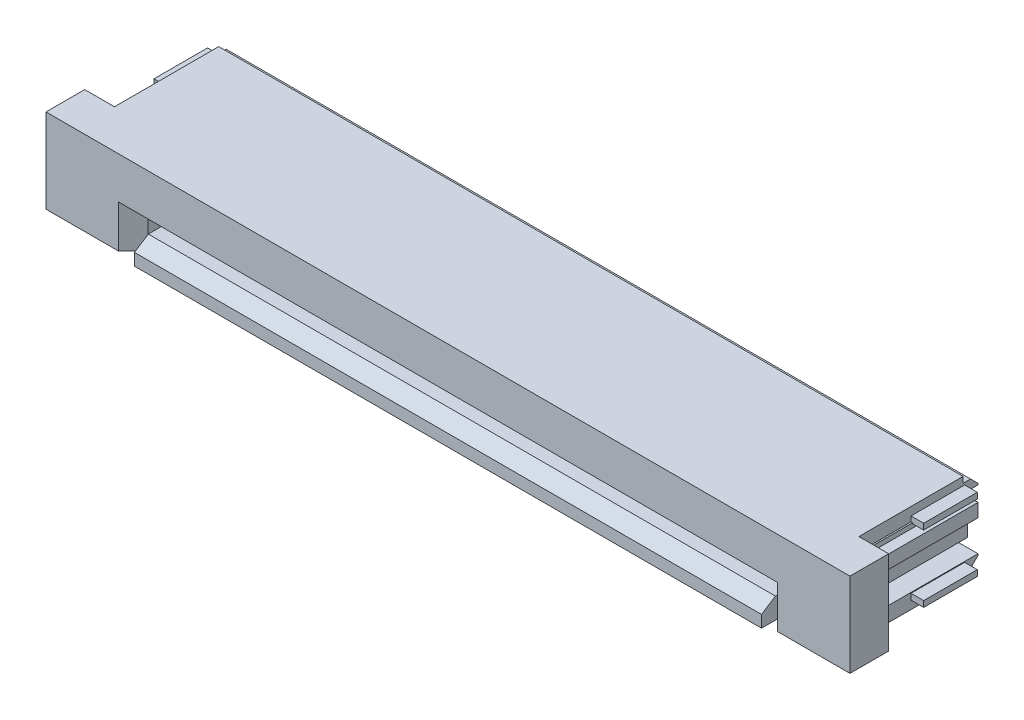
from build123d import *

# Parameters (mm, degrees)
BASE_DEPTH              = 12.5
SKETCH2_W               = 21.2
SKETCH2_H               = 1.55
CARD_SLOT_DEPTH         = 3.8
SKETCH4_W               = 1.775
SKETCH4_H               = 2
WINGS_DEPTH             = 5
SKETCH5_W               = 1.97
SKETCH5_H               = 3
FRONT_LEAD_IN_DEPTH     = 1.3
CARD_SLOT_LEAD_IN_SIZE  = 0.1
CARD_SLOT_LEAD_IN_SIZE2 = 0.173205081
WT_DEPTH                = 1.8
GATE_DEPTH              = 1.3
GATE_CHAMFER_SIZE       = 0.5
GATE_GUIDE_DEPTH        = 3.6
F_01_CONTACT_DEPTH      = 0.125
LPATTERN3_COUNT         = 20
LPATTERN3_PITCH         = 1


with BuildPart() as part:
    # Sketch1 → Base (new body, symmetric)
    with BuildSketch(Plane(origin=(0, 0, 0), x_dir=(0, 0, -1), z_dir=(1, 0, 0))):
        Polygon((-1.75, 1.5), (1.75, 1.5), (1.75, 1.3), (2, 1.3), (2.25, 1.05), (2.25, -1.05), (2, -1.3), (1.75, -1.3), (1.75, -1.5), (-3.05, -1.5), (-3.05, -1.1), (-2.35, -0.65), (-1.75, -0.65), align=None)
    extrude(amount=BASE_DEPTH, both=True)

    # Sketch2 → Card Slot (cut)
    with BuildSketch(Plane.XY.offset(3.05)):
        with Locations((0, -0.025)):
            Rectangle(SKETCH2_W, SKETCH2_H)
    extrude(amount=-CARD_SLOT_DEPTH, mode=Mode.SUBTRACT)

    # Sketch4 → Wings (cut, through all)
    with BuildSketch(Plane.XY.offset(1.75)):
        with Locations((-11.6125, 0)):
            Rectangle(SKETCH4_W, SKETCH4_H)
        with Locations((11.6125, 0)):
            Rectangle(SKETCH4_W, SKETCH4_H)
    extrude(amount=-WINGS_DEPTH, mode=Mode.SUBTRACT)

    # Sketch5 → Front Lead In (cut)
    with BuildSketch(Plane.XY.offset(3.05)):
        with Locations((-11.515, 0)):
            Rectangle(SKETCH5_W, SKETCH5_H)
        with Locations((11.515, 0)):
            Rectangle(SKETCH5_W, SKETCH5_H)
    extrude(amount=-FRONT_LEAD_IN_DEPTH, mode=Mode.SUBTRACT)

    # Card Slot Lead In
    card_slot_lead_in_edges = [part.edges().sort_by_distance(p)[0] for p in [
        (0, 0.75, 1.75),
        (-10.6, -0.025, 1.75),
        (10.6, -0.025, 1.75),
    ]]
    card_slot_lead_in_side = [part.faces().sort_by_distance(p)[0] for p in [
        (0, 0.875692186, 1.75),
    ]]
    chamfer(card_slot_lead_in_edges, length=CARD_SLOT_LEAD_IN_SIZE, length2=CARD_SLOT_LEAD_IN_SIZE2, reference=card_slot_lead_in_side[0])

    # Sketch8 → WT (add)
    with BuildSketch(Plane.XY):
        with BuildLine():
            Line((-12.925, 1.025), (-11.075, 1.025))
            ThreePointArc((-11.075, 1.025), (-10.968933983, 0.981066017), (-10.925, 0.875))
            Line((-10.925, 0.875), (-10.925, -0.875))
            ThreePointArc((-10.925, -0.875), (-10.968933983, -0.981066017), (-11.075, -1.025))
            Line((-11.075, -1.025), (-12.925, -1.025))
            Line((-12.925, -1.025), (-12.925, -1.225))
            Line((-12.925, -1.225), (-11.075, -1.225))
            ThreePointArc((-11.075, -1.225), (-10.827512627, -1.122487373), (-10.725, -0.875))
            Line((-10.725, -0.875), (-10.725, 0.875))
            ThreePointArc((-10.725, 0.875), (-10.827512627, 1.122487373), (-11.075, 1.225))
            Line((-11.075, 1.225), (-12.925, 1.225))
            Line((-12.925, 1.225), (-12.925, 1.025))
        make_face()
        with BuildLine():
            Line((12.925, 1.025), (11.075, 1.025))
            ThreePointArc((11.075, 1.025), (10.968933983, 0.981066017), (10.925, 0.875))
            Line((10.925, 0.875), (10.925, -0.875))
            ThreePointArc((10.925, -0.875), (10.968933983, -0.981066017), (11.075, -1.025))
            Line((11.075, -1.025), (12.925, -1.025))
            Line((12.925, -1.025), (12.925, -1.225))
            Line((12.925, -1.225), (11.075, -1.225))
            ThreePointArc((11.075, -1.225), (10.827512627, -1.122487373), (10.725, -0.875))
            Line((10.725, -0.875), (10.725, 0.875))
            ThreePointArc((10.725, 0.875), (10.827512627, 1.122487373), (11.075, 1.225))
            Line((11.075, 1.225), (12.925, 1.225))
            Line((12.925, 1.225), (12.925, 1.025))
        make_face()
    extrude(amount=-WT_DEPTH)

    # Sketch9 → Gate (add)
    with BuildSketch(Plane.XY.offset(1.75)):
        Polygon((10.57, 0.1), (10.57, -1.33), (13.5, -1.33), (13.5, 1.5), (-13.5, 1.5), (-13.5, -1.33), (-10.57, -1.33), (-10.57, 0.1), align=None)
    extrude(amount=GATE_DEPTH)

    # Gate Chamfer
    gate_chamfer_edges = [part.edges().sort_by_distance(p)[0] for p in [
        (-10.57, -0.615, 3.05),
        (10.57, -0.615, 3.05),
    ]]
    chamfer(gate_chamfer_edges, length=GATE_CHAMFER_SIZE)

    # Sketch10 → Gate Guide (add)
    with BuildSketch(Plane(origin=(0, 0, 1.75), x_dir=(-1, 0, 0), z_dir=(0, 0, -1))):
        Polygon((-12.55, -0.3), (-12.55, 0.44506), (-12.9, 0.44506), (-12.9, 0.89506), (-12.55, 0.89506), (-12.55, 1.05), (-11.9, 1.05), (-11.9, 0.375499815), (-11.625, 0.375499815), (-11.625, -0.201850454), (-12, -0.201850454), (-12, -0.3), align=None)
        Polygon((11.625, -0.201850454), (11.625, 0.375499815), (11.9, 0.375499815), (11.9, 1.05), (12.55, 1.05), (12.55, 0.89506), (12.9, 0.89506), (12.9, 0.44506), (12.55, 0.44506), (12.55, -0.3), (12, -0.3), (12, -0.201850454), align=None)
    extrude(amount=GATE_GUIDE_DEPTH)

    # Sketch13 → -01 Contact (add, symmetric)
    with BuildSketch(Plane(origin=(9.5, 0, 0), x_dir=(0, 0, -1), z_dir=(1, 0, 0))):
        with BuildLine():
            ThreePointArc((1.091468707, -0.7696), (1.268245402, -0.696376695), (1.341468707, -0.5196))
            Line((1.341468707, -0.5196), (1.341468707, -0.44900832))
            ThreePointArc((1.341468707, -0.44900832), (1.111505179, 0.091419351), (0.562636527, 0.300437279))
            Line((0.562636527, 0.300437279), (-1.104507646, 0.2363))
            ThreePointArc((-1.104507646, 0.2363), (-1.202075654, 0.195944223), (-1.25, 0.101862545))
            ThreePointArc((-1.25, 0.101862545), (-1.295444824, 0.048293017), (-1.362451828, 0.069387751))
            Line((-1.362451828, 0.069387751), (-1.649820024, 0.424987751))
            ThreePointArc((-1.649820024, 0.424987751), (-1.649328111, 0.505413401), (-1.570395768, 0.520847536))
            ThreePointArc((-1.570395768, 0.520847536), (-1.36954416, 0.449036779), (-1.1564545, 0.4395))
            Line((-1.1564545, 0.4395), (1.138268707, 0.6804))
            Line((1.138268707, 0.6804), (1.551768707, 0.6804))
            ThreePointArc((1.551768707, 0.6804), (1.650551525, 0.639482817), (1.691468707, 0.5407))
            ThreePointArc((1.691468707, 0.5407), (1.830262642, 0.551847257), (1.896637232, 0.67425))
            Line((1.896637232, 0.67425), (1.896637232, 0.677234263))
            ThreePointArc((1.896637232, 0.677234263), (2.07345297, 0.85405), (2.250268707, 0.677234263))
            Line((2.250268707, 0.677234263), (2.250268707, 0.324203125))
            ThreePointArc((2.250268707, 0.324203125), (2.212168707, 0.2234), (2.250268707, 0.122596875))
            Line((2.250268707, 0.122596875), (2.250268707, -0.561796875))
            ThreePointArc((2.250268707, -0.561796875), (2.225665582, -0.725303125), (2.364568707, -0.815))
            Line((2.364568707, -0.815), (2.505907985, -0.815))
            ThreePointArc((2.505907985, -0.815), (2.630745337, -0.837012193), (2.740525462, -0.900393778))
            Line((2.740525462, -0.900393778), (3.069017668, -1.176031466))
            ThreePointArc((3.069017668, -1.176031466), (3.12631387, -1.209111444), (3.191468707, -1.2206))
            Line((3.191468707, -1.2206), (3.648668707, -1.2206))
            ThreePointArc((3.648668707, -1.2206), (3.720510756, -1.250357951), (3.750268707, -1.3222))
            Line((3.750268707, -1.3222), (3.750268707, -1.3984))
            ThreePointArc((3.750268707, -1.3984), (3.720510756, -1.470242049), (3.648668707, -1.5))
            Line((3.648668707, -1.5), (3.191468707, -1.5))
            ThreePointArc((3.191468707, -1.5), (3.030753442, -1.471661563), (2.889422809, -1.390064284))
            Line((2.889422809, -1.390064284), (2.60967503, -1.155328025))
            ThreePointArc((2.60967503, -1.155328025), (2.402653987, -1.096846191), (2.221577699, -1.21298927))
            ThreePointArc((2.221577699, -1.21298927), (2.023089184, -1.285925543), (1.896637232, -1.116434263))
            Line((1.896637232, -1.116434263), (1.896637232, -1.11345))
            ThreePointArc((1.896637232, -1.11345), (1.830262642, -0.991047257), (1.691468707, -0.9799))
            ThreePointArc((1.691468707, -0.9799), (1.650551525, -1.078682817), (1.551768707, -1.1196))
            Line((1.551768707, -1.1196), (-1.375731293, -1.1196))
            ThreePointArc((-1.375731293, -1.1196), (-1.44817573, -1.064011428), (-1.413231293, -0.979648095))
            Line((-1.413231293, -0.979648095), (-1.066821131, -0.779648095))
            ThreePointArc((-1.066821131, -0.779648095), (-1.04873256, -0.772155563), (-1.029321131, -0.7696))
            Line((-1.029321131, -0.7696), (1.091468707, -0.7696))
        make_face()
    f_01_contact = extrude(amount=F_01_CONTACT_DEPTH, both=True)

    # LPattern3: -01 Contact ×20
    with Locations(*[(-i * LPATTERN3_PITCH, 0, 0) for i in range(1, LPATTERN3_COUNT)]):
        add(f_01_contact)


solid = part.part
